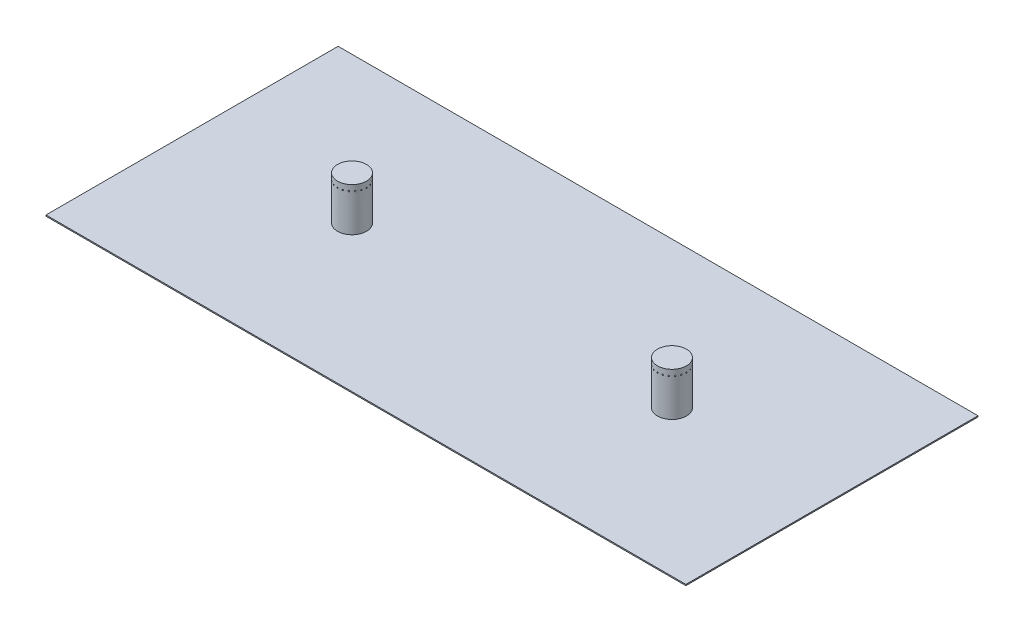
from build123d import *

# Parameters (mm, degrees)
SKETCH1_W                = 1104
SKETCH1_H                = 504
BOSS_EXTRUDE1_DEPTH      = 2
SKETCH2_R                = 25
BOSS_EXTRUDE2_DEPTH      = 75
SKETCH3_R                = 1
CUT_EXTRUDE1_DEPTH       = 5
CIRPATTERN1_COUNT        = 20
MIRROR2_COPY_1_SKETCH_R  = 1
MIRROR2_COPY_1_DEPTH     = 5
MIRROR2_COPY_2_SKETCH_R  = 1
MIRROR2_COPY_2_DEPTH     = 5
MIRROR2_COPY_3_SKETCH_R  = 1
MIRROR2_COPY_3_DEPTH     = 5
MIRROR2_COPY_4_SKETCH_R  = 1
MIRROR2_COPY_4_DEPTH     = 5
MIRROR2_COPY_5_SKETCH_R  = 1
MIRROR2_COPY_5_DEPTH     = 5
MIRROR2_COPY_6_SKETCH_R  = 1
MIRROR2_COPY_6_DEPTH     = 5
MIRROR2_COPY_7_SKETCH_R  = 1
MIRROR2_COPY_7_DEPTH     = 5
MIRROR2_COPY_8_SKETCH_R  = 1
MIRROR2_COPY_8_DEPTH     = 5
MIRROR2_COPY_9_SKETCH_R  = 1
MIRROR2_COPY_9_DEPTH     = 5
MIRROR2_COPY_10_SKETCH_R = 1
MIRROR2_COPY_10_DEPTH    = 5
MIRROR2_COPY_11_SKETCH_R = 1
MIRROR2_COPY_11_DEPTH    = 5
MIRROR2_COPY_12_SKETCH_R = 1
MIRROR2_COPY_12_DEPTH    = 5
MIRROR2_COPY_13_SKETCH_R = 1
MIRROR2_COPY_13_DEPTH    = 5
MIRROR2_COPY_14_SKETCH_R = 1
MIRROR2_COPY_14_DEPTH    = 5
MIRROR2_COPY_15_SKETCH_R = 1
MIRROR2_COPY_15_DEPTH    = 5
MIRROR2_COPY_16_SKETCH_R = 1
MIRROR2_COPY_16_DEPTH    = 5
MIRROR2_COPY_17_SKETCH_R = 1
MIRROR2_COPY_17_DEPTH    = 5
MIRROR2_COPY_18_SKETCH_R = 1
MIRROR2_COPY_18_DEPTH    = 5
MIRROR2_COPY_19_SKETCH_R = 1
MIRROR2_COPY_19_DEPTH    = 5


with BuildPart() as part:
    # Sketch1 → Boss-Extrude1 (new body)
    with BuildSketch(Plane(origin=(0, 0, 0), x_dir=(1, 0, 0), z_dir=(0, 1, 0))):
        Rectangle(SKETCH1_W, SKETCH1_H)
    extrude(amount=BOSS_EXTRUDE1_DEPTH)

    # Sketch2 → Boss-Extrude2 (add)
    with BuildSketch(Plane(origin=(0, 2, 0), x_dir=(1, 0, 0), z_dir=(0, 1, 0))):
        with Locations((-276, 0)):
            Circle(SKETCH2_R)
    boss_extrude2 = extrude(amount=BOSS_EXTRUDE2_DEPTH)

    # Sketch3 → Cut-Extrude1 (cut)
    with BuildSketch(Plane.XY.offset(25)):
        with Locations((-276, 67)):
            Circle(SKETCH3_R)
    cut_extrude1 = extrude(amount=-CUT_EXTRUDE1_DEPTH, mode=Mode.SUBTRACT)

    # CirPattern1: Cut-Extrude1 ×20 about axis
    cirpattern1_axis = Axis((-276, 0, 0), (0, 1, 0))
    for i in range(1, CIRPATTERN1_COUNT):
        add(cut_extrude1.rotate(cirpattern1_axis, i * 360 / CIRPATTERN1_COUNT), mode=Mode.SUBTRACT)

    # Mirror1: Boss-Extrude2 across plane
    add(boss_extrude2.mirror(Plane(origin=(0, 0, 0), x_dir=(0, 0, 1), z_dir=(1, 0, 0))))

    # Mirror2: Cut-Extrude1 across plane
    add(cut_extrude1.mirror(Plane(origin=(0, 0, 0), x_dir=(0, 0, 1), z_dir=(1, 0, 0))), mode=Mode.SUBTRACT)

    # Mirror2 copy 1 sketch → Mirror2 copy 1 (cut)
    with BuildSketch(Plane(origin=(5.782976643, 0, -61.51227754), x_dir=(-0.951056516, 0, -0.309016994), z_dir=(-0.309016994, 0, 0.951056516))):
        with Locations((-276, -67)):
            Circle(MIRROR2_COPY_1_SKETCH_R)
    extrude(amount=-MIRROR2_COPY_1_DEPTH, mode=Mode.SUBTRACT)

    # Mirror2 copy 2 sketch → Mirror2 copy 2 (cut)
    with BuildSketch(Plane(origin=(38.016678245, 0, -142.003304773), x_dir=(-0.809016994, 0, -0.587785252), z_dir=(-0.587785252, 0, 0.809016994))):
        with Locations((-276, -67)):
            Circle(MIRROR2_COPY_2_SKETCH_R)
    extrude(amount=-MIRROR2_COPY_2_DEPTH, mode=Mode.SUBTRACT)

    # Mirror2 copy 3 sketch → Mirror2 copy 3 (cut)
    with BuildSketch(Plane(origin=(93.545845508, 0, -208.59405914), x_dir=(-0.587785252, 0, -0.809016994), z_dir=(-0.809016994, 0, 0.587785252))):
        with Locations((-276, -67)):
            Circle(MIRROR2_COPY_3_SKETCH_R)
    extrude(amount=-MIRROR2_COPY_3_DEPTH, mode=Mode.SUBTRACT)

    # Mirror2 copy 4 sketch → Mirror2 copy 4 (cut)
    with BuildSketch(Plane(origin=(166.934896645, 0, -254.766173638), x_dir=(-0.309016994, 0, -0.951056516), z_dir=(-0.951056516, 0, 0.309016994))):
        with Locations((-276, -67)):
            Circle(MIRROR2_COPY_4_SKETCH_R)
    extrude(amount=-MIRROR2_COPY_4_DEPTH, mode=Mode.SUBTRACT)

    # Mirror2 copy 5 sketch → Mirror2 copy 5 (cut)
    with BuildSketch(Plane(origin=(251, 0, -276), x_dir=(0, 0, -1), z_dir=(-1, 0, 0))):
        with Locations((-276, -67)):
            Circle(MIRROR2_COPY_5_SKETCH_R)
    extrude(amount=-MIRROR2_COPY_5_DEPTH, mode=Mode.SUBTRACT)

    # Mirror2 copy 6 sketch → Mirror2 copy 6 (cut)
    with BuildSketch(Plane(origin=(337.51227754, 0, -270.217023357), x_dir=(0.309016994, 0, -0.951056516), z_dir=(-0.951056516, 0, -0.309016994))):
        with Locations((-276, -67)):
            Circle(MIRROR2_COPY_6_SKETCH_R)
    extrude(amount=-MIRROR2_COPY_6_DEPTH, mode=Mode.SUBTRACT)

    # Mirror2 copy 7 sketch → Mirror2 copy 7 (cut)
    with BuildSketch(Plane(origin=(418.003304773, 0, -237.983321755), x_dir=(0.587785252, 0, -0.809016994), z_dir=(-0.809016994, 0, -0.587785252))):
        with Locations((-276, -67)):
            Circle(MIRROR2_COPY_7_SKETCH_R)
    extrude(amount=-MIRROR2_COPY_7_DEPTH, mode=Mode.SUBTRACT)

    # Mirror2 copy 8 sketch → Mirror2 copy 8 (cut)
    with BuildSketch(Plane(origin=(484.59405914, 0, -182.454154492), x_dir=(0.809016994, 0, -0.587785252), z_dir=(-0.587785252, 0, -0.809016994))):
        with Locations((-276, -67)):
            Circle(MIRROR2_COPY_8_SKETCH_R)
    extrude(amount=-MIRROR2_COPY_8_DEPTH, mode=Mode.SUBTRACT)

    # Mirror2 copy 9 sketch → Mirror2 copy 9 (cut)
    with BuildSketch(Plane(origin=(530.766173638, 0, -109.065103355), x_dir=(0.951056516, 0, -0.309016994), z_dir=(-0.309016994, 0, -0.951056516))):
        with Locations((-276, -67)):
            Circle(MIRROR2_COPY_9_SKETCH_R)
    extrude(amount=-MIRROR2_COPY_9_DEPTH, mode=Mode.SUBTRACT)

    # Mirror2 copy 10 sketch → Mirror2 copy 10 (cut)
    with BuildSketch(Plane(origin=(552, 0, -25), x_dir=(1, 0, 0), z_dir=(0, 0, -1))):
        with Locations((-276, -67)):
            Circle(MIRROR2_COPY_10_SKETCH_R)
    extrude(amount=-MIRROR2_COPY_10_DEPTH, mode=Mode.SUBTRACT)

    # Mirror2 copy 11 sketch → Mirror2 copy 11 (cut)
    with BuildSketch(Plane(origin=(546.217023357, 0, 61.51227754), x_dir=(0.951056516, 0, 0.309016994), z_dir=(0.309016994, 0, -0.951056516))):
        with Locations((-276, -67)):
            Circle(MIRROR2_COPY_11_SKETCH_R)
    extrude(amount=-MIRROR2_COPY_11_DEPTH, mode=Mode.SUBTRACT)

    # Mirror2 copy 12 sketch → Mirror2 copy 12 (cut)
    with BuildSketch(Plane(origin=(513.983321755, 0, 142.003304773), x_dir=(0.809016994, 0, 0.587785252), z_dir=(0.587785252, 0, -0.809016994))):
        with Locations((-276, -67)):
            Circle(MIRROR2_COPY_12_SKETCH_R)
    extrude(amount=-MIRROR2_COPY_12_DEPTH, mode=Mode.SUBTRACT)

    # Mirror2 copy 13 sketch → Mirror2 copy 13 (cut)
    with BuildSketch(Plane(origin=(458.454154492, 0, 208.59405914), x_dir=(0.587785252, 0, 0.809016994), z_dir=(0.809016994, 0, -0.587785252))):
        with Locations((-276, -67)):
            Circle(MIRROR2_COPY_13_SKETCH_R)
    extrude(amount=-MIRROR2_COPY_13_DEPTH, mode=Mode.SUBTRACT)

    # Mirror2 copy 14 sketch → Mirror2 copy 14 (cut)
    with BuildSketch(Plane(origin=(385.065103355, 0, 254.766173638), x_dir=(0.309016994, 0, 0.951056516), z_dir=(0.951056516, 0, -0.309016994))):
        with Locations((-276, -67)):
            Circle(MIRROR2_COPY_14_SKETCH_R)
    extrude(amount=-MIRROR2_COPY_14_DEPTH, mode=Mode.SUBTRACT)

    # Mirror2 copy 15 sketch → Mirror2 copy 15 (cut)
    with BuildSketch(Plane(origin=(301, 0, 276), x_dir=(0, 0, 1), z_dir=(1, 0, 0))):
        with Locations((-276, -67)):
            Circle(MIRROR2_COPY_15_SKETCH_R)
    extrude(amount=-MIRROR2_COPY_15_DEPTH, mode=Mode.SUBTRACT)

    # Mirror2 copy 16 sketch → Mirror2 copy 16 (cut)
    with BuildSketch(Plane(origin=(214.48772246, 0, 270.217023357), x_dir=(-0.309016994, 0, 0.951056516), z_dir=(0.951056516, 0, 0.309016994))):
        with Locations((-276, -67)):
            Circle(MIRROR2_COPY_16_SKETCH_R)
    extrude(amount=-MIRROR2_COPY_16_DEPTH, mode=Mode.SUBTRACT)

    # Mirror2 copy 17 sketch → Mirror2 copy 17 (cut)
    with BuildSketch(Plane(origin=(133.996695227, 0, 237.983321755), x_dir=(-0.587785252, 0, 0.809016994), z_dir=(0.809016994, 0, 0.587785252))):
        with Locations((-276, -67)):
            Circle(MIRROR2_COPY_17_SKETCH_R)
    extrude(amount=-MIRROR2_COPY_17_DEPTH, mode=Mode.SUBTRACT)

    # Mirror2 copy 18 sketch → Mirror2 copy 18 (cut)
    with BuildSketch(Plane(origin=(67.40594086, 0, 182.454154492), x_dir=(-0.809016994, 0, 0.587785252), z_dir=(0.587785252, 0, 0.809016994))):
        with Locations((-276, -67)):
            Circle(MIRROR2_COPY_18_SKETCH_R)
    extrude(amount=-MIRROR2_COPY_18_DEPTH, mode=Mode.SUBTRACT)

    # Mirror2 copy 19 sketch → Mirror2 copy 19 (cut)
    with BuildSketch(Plane(origin=(21.233826362, 0, 109.065103355), x_dir=(-0.951056516, 0, 0.309016994), z_dir=(0.309016994, 0, 0.951056516))):
        with Locations((-276, -67)):
            Circle(MIRROR2_COPY_19_SKETCH_R)
    extrude(amount=-MIRROR2_COPY_19_DEPTH, mode=Mode.SUBTRACT)


solid = part.part
